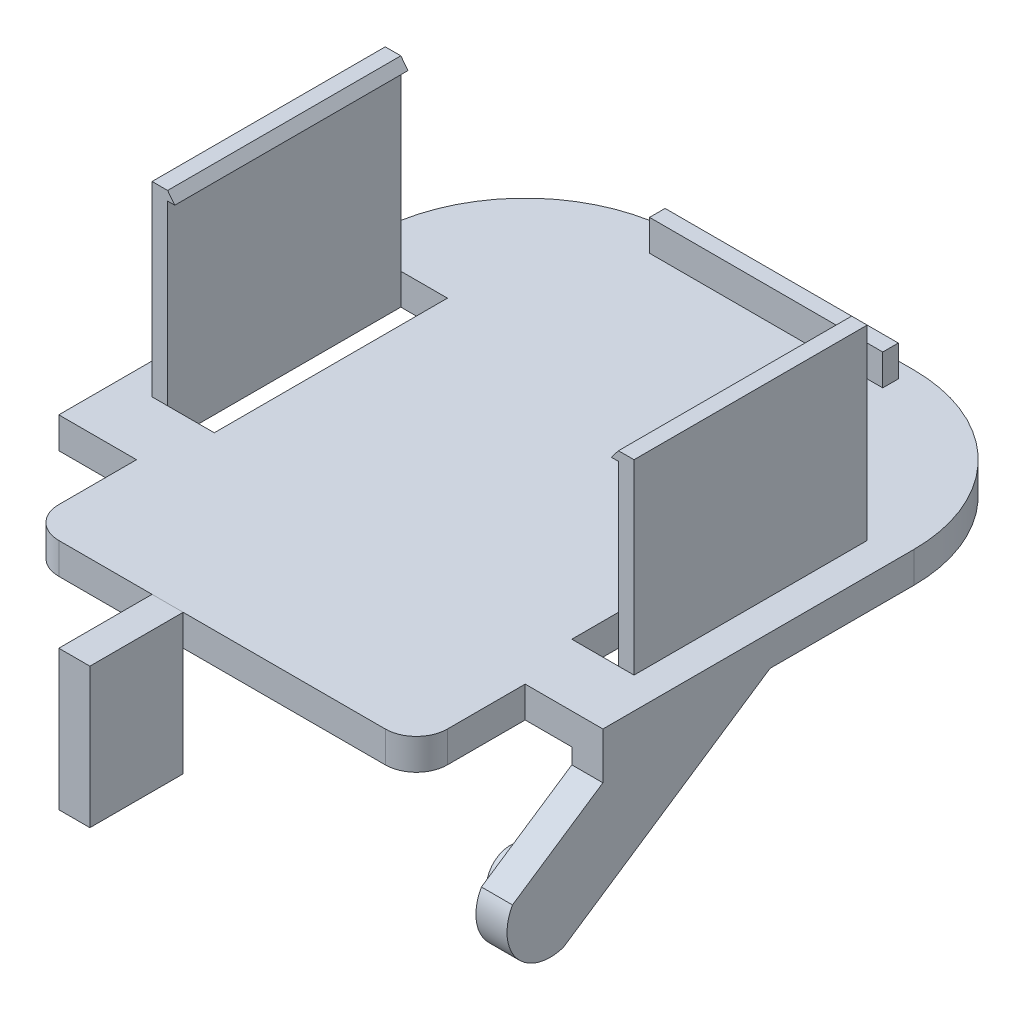
from build123d import *

# Parameters (mm, degrees)
SKETCH1_W           = 35
SKETCH1_H           = 37
BOSS_EXTRUDE1_DEPTH = 2
FILLET1_R           = 10
SKETCH2_W           = 15
SKETCH2_H           = 1
BOSS_EXTRUDE2_DEPTH = 2
CUT_EXTRUDE1_REACH  = 4
SKETCH3_W           = 5
SKETCH3_H           = 7
FILLET2_R           = 2
BOSS_EXTRUDE3_DEPTH = 2
SKETCH5_R           = 1.5
BOSS_EXTRUDE4_DEPTH = 3
SKETCH6_W           = 1
SKETCH6_H           = 15
BOSS_EXTRUDE5_DEPTH = 12
BOSS_EXTRUDE6_DEPTH = 15
SKETCH8_W           = 3
SKETCH8_H           = 15
CUT_EXTRUDE4_DEPTH  = 2
SKETCH11_W          = 2
SKETCH11_H          = 6
BOSS_EXTRUDE8_DEPTH = 9


with BuildPart() as part:
    # Sketch1 → Boss-Extrude1 (new body)
    with BuildSketch(Plane(origin=(0, 0, 0), x_dir=(1, 0, 0), z_dir=(0, 1, 0))):
        Rectangle(SKETCH1_W, SKETCH1_H)
    extrude(amount=BOSS_EXTRUDE1_DEPTH)

    # Fillet1
    fillet1_edges = [part.edges().sort_by_distance(p)[0] for p in [
        (-17.5, 1, -18.5),
        (17.5, 1, -18.5),
    ]]
    fillet(fillet1_edges, radius=FILLET1_R)

    # Sketch2 → Boss-Extrude2 (add)
    with BuildSketch(Plane(origin=(0, 2, 0), x_dir=(1, 0, 0), z_dir=(0, 1, 0))):
        with Locations((0, 17)):
            Rectangle(SKETCH2_W, SKETCH2_H)
    extrude(amount=BOSS_EXTRUDE2_DEPTH)

    # Sketch3 → Cut-Extrude1 (cut, up to next)
    with BuildSketch(Plane(origin=(0, 2, 0), x_dir=(1, 0, 0), z_dir=(0, 1, 0)), mode=Mode.PRIVATE) as cut_extrude1_sk1:
        with Locations((15, -15)):
            Rectangle(SKETCH3_W, SKETCH3_H)
    cut_extrude1_tool1 = extrude(cut_extrude1_sk1.sketch, amount=-CUT_EXTRUDE1_REACH, mode=Mode.PRIVATE) & part.part
    add(cut_extrude1_tool1.solids().sort_by_distance((15, 2, 15))[0], mode=Mode.SUBTRACT)
    # Sketch3 → Cut-Extrude1 (cut, up to next)
    with BuildSketch(Plane(origin=(0, 2, 0), x_dir=(1, 0, 0), z_dir=(0, 1, 0)), mode=Mode.PRIVATE) as cut_extrude1_sk2:
        with Locations((-15, -15)):
            Rectangle(SKETCH3_W, SKETCH3_H)
    cut_extrude1_tool2 = extrude(cut_extrude1_sk2.sketch, amount=-CUT_EXTRUDE1_REACH, mode=Mode.PRIVATE) & part.part
    add(cut_extrude1_tool2.solids().sort_by_distance((-15, 2, 15))[0], mode=Mode.SUBTRACT)

    # Fillet2
    fillet2_edges = [part.edges().sort_by_distance(p)[0] for p in [
        (12.5, 1, 18.5),
        (-12.5, 1, 18.5),
    ]]
    fillet(fillet2_edges, radius=FILLET2_R)

    # Sketch4 → Boss-Extrude3 (add)
    with BuildSketch(Plane(origin=(17.5, 0, 0), x_dir=(0, 0, -1), z_dir=(1, 0, 0))):
        with BuildLine():
            Line((-11.5, 0), (-11.5, -1))
            Line((-11.5, -1), (-17.31755328, -4.893080251))
            ThreePointArc((-17.31755328, -4.893080251), (-17.042817275, -8.006709978), (-14.046997598, -8.898469144))
            Line((-14.046997598, -8.898469144), (-0.749732959, 0))
            Line((-0.749732959, 0), (-11.5, 0))
        make_face()
    extrude(amount=-BOSS_EXTRUDE3_DEPTH)

    # Sketch5 → Boss-Extrude4 (add)
    with BuildSketch(Plane(origin=(17.5, 0, 0), x_dir=(0, 0, -1), z_dir=(1, 0, 0))):
        with Locations((-14.476503348, -6)):
            Circle(SKETCH5_R)
    extrude(amount=-BOSS_EXTRUDE4_DEPTH)

    # Sketch6 → Boss-Extrude5 (add)
    with BuildSketch(Plane(origin=(0, 2, 0), x_dir=(1, 0, 0), z_dir=(0, 1, 0))):
        with Locations((15, 0)):
            Rectangle(SKETCH6_W, SKETCH6_H)
        with Locations((-15, 0)):
            Rectangle(SKETCH6_W, SKETCH6_H)
    extrude(amount=BOSS_EXTRUDE5_DEPTH)

    # Sketch7 → Boss-Extrude6 (add)
    with BuildSketch(Plane.XY.offset(7.5)):
        Polygon((-14.5, 14), (-14.037063051, 13.408338163), (-14.5, 13.408338163), align=None)
    boss_extrude6 = extrude(amount=-BOSS_EXTRUDE6_DEPTH)

    # Mirror1: Boss-Extrude6 across plane
    add(boss_extrude6.mirror(Plane(origin=(0, 0, 0), x_dir=(0, 0, 1), z_dir=(1, 0, 0))))

    # Sketch8 → Cut-Extrude4 (cut)
    with BuildSketch(Plane(origin=(0, 2, 0), x_dir=(1, 0, 0), z_dir=(0, 1, 0))):
        with Locations((-13, 0)):
            Rectangle(SKETCH8_W, SKETCH8_H)
    cut_extrude4 = extrude(amount=-CUT_EXTRUDE4_DEPTH, mode=Mode.SUBTRACT)

    # Mirror2: Cut-Extrude4 across plane
    add(cut_extrude4.mirror(Plane(origin=(0, 0, 0), x_dir=(0, 0, 1), z_dir=(1, 0, 0))), mode=Mode.SUBTRACT)


with BuildPart() as body_2:
    # Sketch11 → Boss-Extrude8 (new body)
    with BuildSketch(Plane(origin=(0, 2, 0), x_dir=(1, 0, 0), z_dir=(0, 1, 0))):
        with Locations((-3.5, -21.5)):
            Rectangle(SKETCH11_W, SKETCH11_H)
    extrude(amount=-BOSS_EXTRUDE8_DEPTH)


solid = Compound([part.part, body_2.part])
